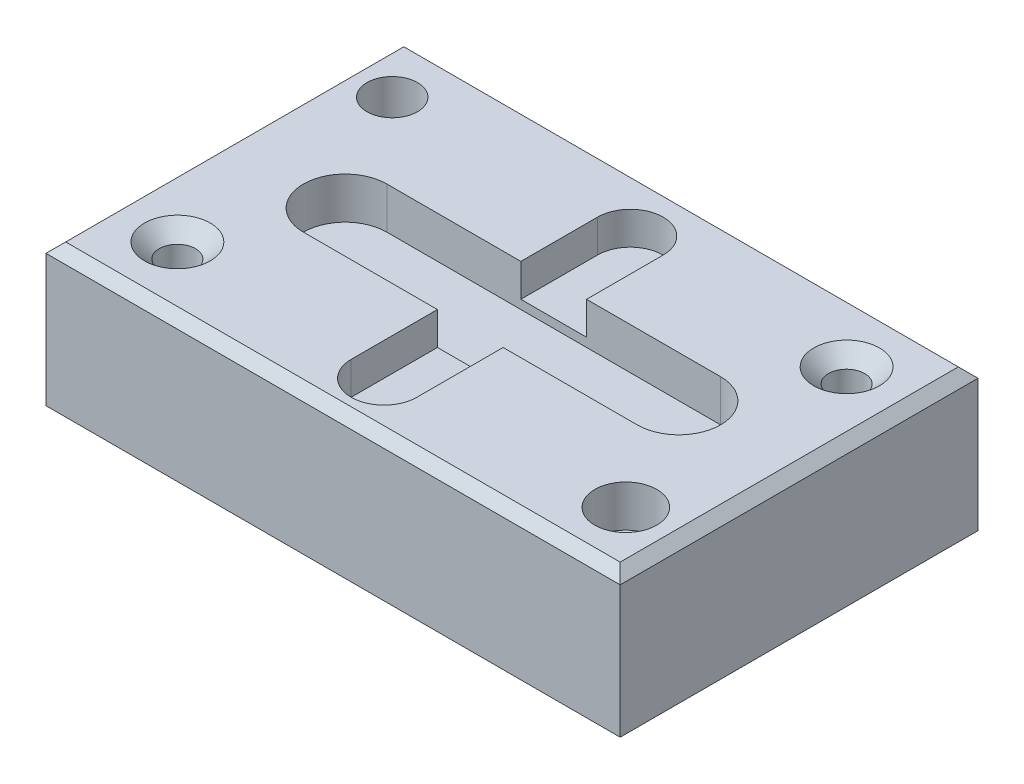
from build123d import *

# Parameters (mm, degrees)
SKETCH1_W                                        = 174.796166906
SKETCH1_H                                        = 108.92723011
BOSS_EXTRUDE1_DEPTH                              = 43.18
SKETCH2_R                                        = 7.697413188
SKETCH2_R_2                                      = 9.430807524
CUT_EXTRUDE1_DEPTH                               = 12.7
CUT_EXTRUDE2_DEPTH                               = 10
CSK_FOR_M10_FLAT_HEAD_MACHINE_SCREW1_D           = 11
CSK_FOR_M10_FLAT_HEAD_MACHINE_SCREW1_DEPTH       = 16.695266595
CSK_FOR_M10_FLAT_HEAD_MACHINE_SCREW1_CSINK_D     = 20
CSK_FOR_M10_FLAT_HEAD_MACHINE_SCREW1_CSINK_ANGLE = 90
CSK_FOR_M10_FLAT_HEAD_MACHINE_SCREW1_TIP         = 3.304733405
CHAMFER1_SIZE                                    = 3


with BuildPart() as part:
    # Sketch1 → Boss-Extrude1 (new body)
    with BuildSketch(Plane(origin=(0, 0, 0), x_dir=(1, 0, 0), z_dir=(0, 1, 0))):
        Rectangle(SKETCH1_W, SKETCH1_H)
    extrude(amount=BOSS_EXTRUDE1_DEPTH)

    # Sketch2 → Cut-Extrude1 (cut)
    with BuildSketch(Plane(origin=(0, 43.18, 0), x_dir=(1, 0, 0), z_dir=(0, 1, 0))):
        with Locations(Location((-72.874036632, 36.40863105, 0), (0, 0, 270))):  # turned: the seam where the file's is
            Circle(SKETCH2_R)
        with Locations(Location((70.801263176, -36.157833353, 0), (0, 0, 270))):  # turned: the seam where the file's is
            Circle(SKETCH2_R_2)
        with BuildLine():
            Line((-50.8, 12.7), (50.8, 12.7))
            ThreePointArc((50.8, 12.7), (63.5, 0), (50.8, -12.7))
            Line((50.8, -12.7), (-50.8, -12.7))
            ThreePointArc((-50.8, -12.7), (-63.5, 0), (-50.8, 12.7))
        make_face()
    extrude(amount=-CUT_EXTRUDE1_DEPTH, mode=Mode.SUBTRACT)

    # Sketch3 → Cut-Extrude2 (cut)
    with BuildSketch(Plane(origin=(0, 43.18, 0), x_dir=(1, 0, 0), z_dir=(0, 1, 0))):
        with BuildLine():
            Line((10, 36.036384945), (10, -38.963615055))
            ThreePointArc((10, -38.963615055), (0, -48.963615055), (-10, -38.963615055))
            Line((-10, -38.963615055), (-10, 36.036384945))
            ThreePointArc((-10, 36.036384945), (0, 46.036384945), (10, 36.036384945))
        make_face()
    extrude(amount=-CUT_EXTRUDE2_DEPTH, mode=Mode.SUBTRACT)

    # CSK for M10 Flat Head Machine Screw1
    with Locations(Plane(origin=(0, 43.18, 0), x_dir=(1, 0, 0), z_dir=(0, 1, 0))):
        with Locations((67.398083453, 34.463615055), (-67.398083453, -34.463615055)):
            CounterSinkHole(CSK_FOR_M10_FLAT_HEAD_MACHINE_SCREW1_D / 2, CSK_FOR_M10_FLAT_HEAD_MACHINE_SCREW1_CSINK_D / 2, depth=CSK_FOR_M10_FLAT_HEAD_MACHINE_SCREW1_DEPTH, counter_sink_angle=CSK_FOR_M10_FLAT_HEAD_MACHINE_SCREW1_CSINK_ANGLE)
            with Locations((0, 0, -(CSK_FOR_M10_FLAT_HEAD_MACHINE_SCREW1_DEPTH + CSK_FOR_M10_FLAT_HEAD_MACHINE_SCREW1_TIP / 2))):  # 118° drill point
                Cone(0, CSK_FOR_M10_FLAT_HEAD_MACHINE_SCREW1_D / 2, CSK_FOR_M10_FLAT_HEAD_MACHINE_SCREW1_TIP, mode=Mode.SUBTRACT)

    # Chamfer1
    chamfer1_edges = [part.edges().sort_by_distance(p)[0] for p in [
        (-87.398083453, 43.18, 0),
        (0, 43.18, 54.463615055),
        (87.398083453, 43.18, 0),
        (0, 43.18, -54.463615055),
    ]]
    chamfer(chamfer1_edges, length=CHAMFER1_SIZE)


solid = part.part
